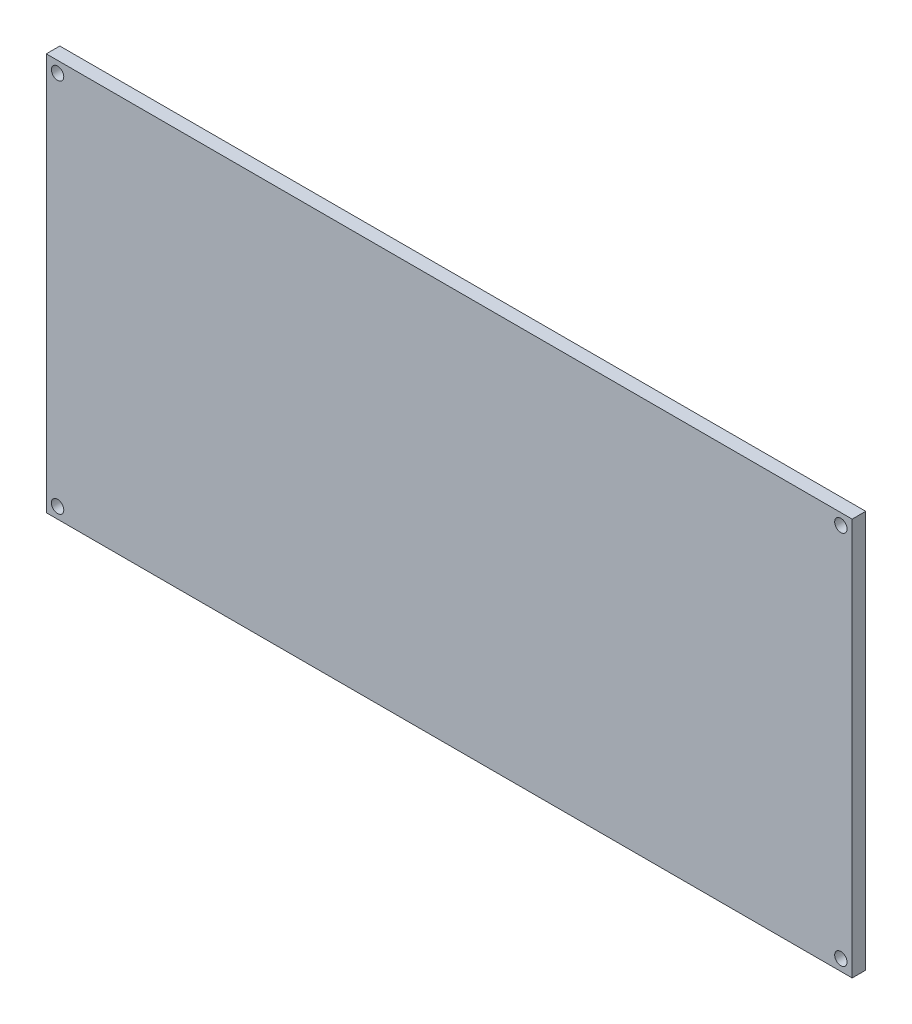
from build123d import *

# Parameters (mm, degrees)
SKETCH1_W           = 188.8
SKETCH1_H           = 93.1
SKETCH1_R           = 1.45
BOSS_EXTRUDE1_DEPTH = 3.175


with BuildPart() as part:
    # Sketch1 → Boss-Extrude1 (new body)
    with BuildSketch(Plane.XY):
        Rectangle(SKETCH1_W, SKETCH1_H)
        with Locations((-91.75, 43.9425)):
            Circle(SKETCH1_R, mode=Mode.SUBTRACT)
        with Locations((91.75, 43.9425)):
            Circle(SKETCH1_R, mode=Mode.SUBTRACT)
        with Locations((91.75, -43.9425)):
            Circle(SKETCH1_R, mode=Mode.SUBTRACT)
        with Locations((-91.75, -43.9425)):
            Circle(SKETCH1_R, mode=Mode.SUBTRACT)
    extrude(amount=BOSS_EXTRUDE1_DEPTH)


solid = part.part
